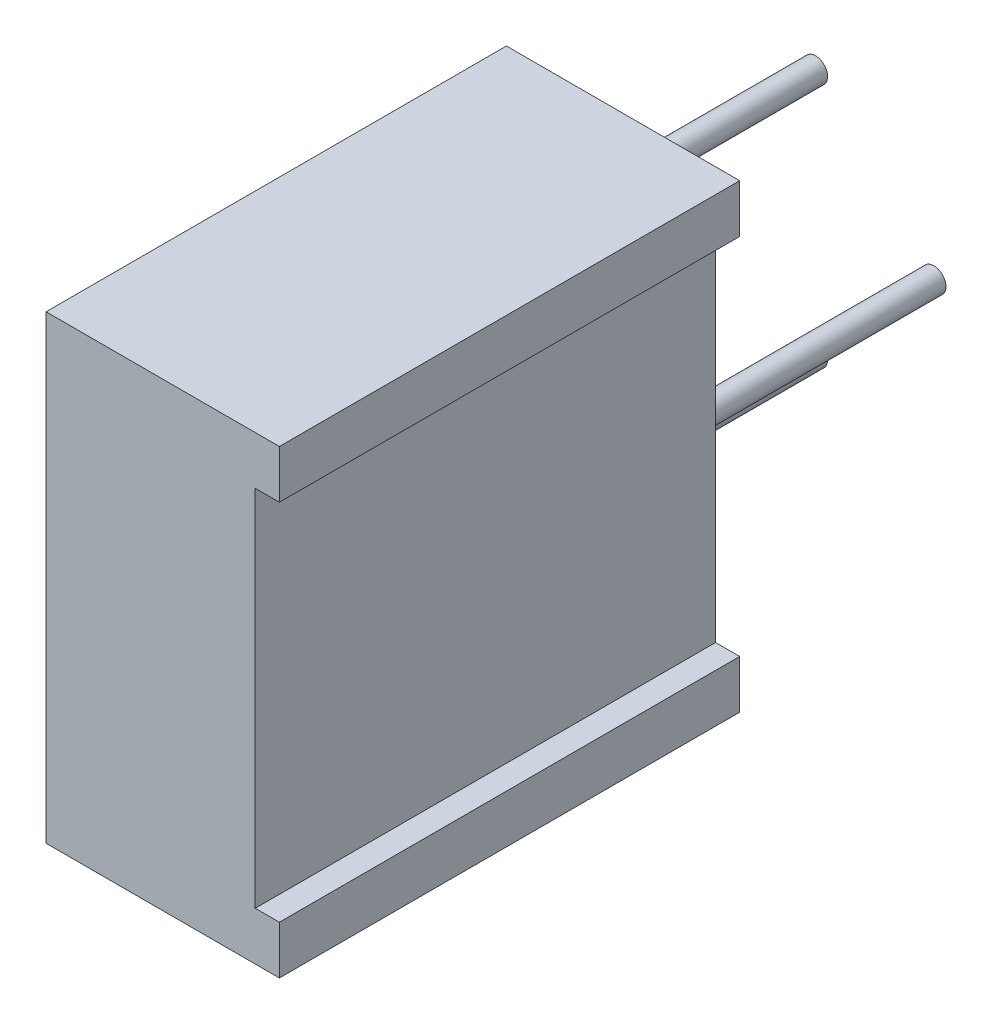
from build123d import *

# Parameters (mm, degrees)
SKETCH1_W           = 9.53
SKETCH1_H           = 9.53
BASIC_SHAPE_DEPTH   = 4.83
SKETCH3_R           = 2
ADJUSTER_DEPTH      = 0.1
ADJUSTER_SLOT_DEPTH = 1
SKETCH5_R           = 0.25
PINS_DEPTH          = 5
SKETCH6_W           = 0.5
SKETCH6_H           = 7.53
REAR_RELIEF_DEPTH   = 15.53


with BuildPart() as part:
    # Sketch1 → Basic Shape (new body)
    with BuildSketch(Plane(origin=(0, 0, 0), x_dir=(0, 0, 1), z_dir=(1, 0, 0))):
        with Locations((4.765, 4.765)):
            Rectangle(SKETCH1_W, SKETCH1_H)
    extrude(amount=BASIC_SHAPE_DEPTH)

    # Sketch3 → Adjuster (cut)
    with BuildSketch(Plane.YZ):
        with Locations((-4.765, 4.765)):
            Circle(SKETCH3_R)
    extrude(amount=ADJUSTER_DEPTH, mode=Mode.SUBTRACT)

    # Sketch4 → Adjuster Slot (cut)
    with BuildSketch(Plane(origin=(0.1, 0, 0), x_dir=(0, -1, 0), z_dir=(-1, 0, 0))):
        with BuildLine():
            Line((3.749246997, 6.487859784), (6.487859784, 3.749246997))
            ThreePointArc((6.487859784, 3.749246997), (6.179213562, 3.350786438), (5.780753003, 3.042140216))
            Line((5.780753003, 3.042140216), (3.042140216, 5.780753003))
            ThreePointArc((3.042140216, 5.780753003), (3.350786438, 6.179213562), (3.749246997, 6.487859784))
        make_face()
    extrude(amount=-ADJUSTER_SLOT_DEPTH, mode=Mode.SUBTRACT)

    # Sketch5 → Pins (add)
    with BuildSketch(Plane(origin=(0, -19.06, 0), x_dir=(0, -1, 0), z_dir=(0, 0, -1))):
        with Locations((-16.835, -1.4)):
            Circle(SKETCH5_R)
        with Locations((-14.295, -3.85)):
            Circle(SKETCH5_R)
        with Locations((-11.755, -1.4)):
            Circle(SKETCH5_R)
    extrude(amount=PINS_DEPTH)

    # Sketch6 → Rear Relief (cut, through all)
    with BuildSketch(Plane.XY.offset(9.53)):
        with Locations((4.58, -4.765)):
            Rectangle(SKETCH6_W, SKETCH6_H)
    extrude(amount=-REAR_RELIEF_DEPTH, mode=Mode.SUBTRACT)


solid = part.part
